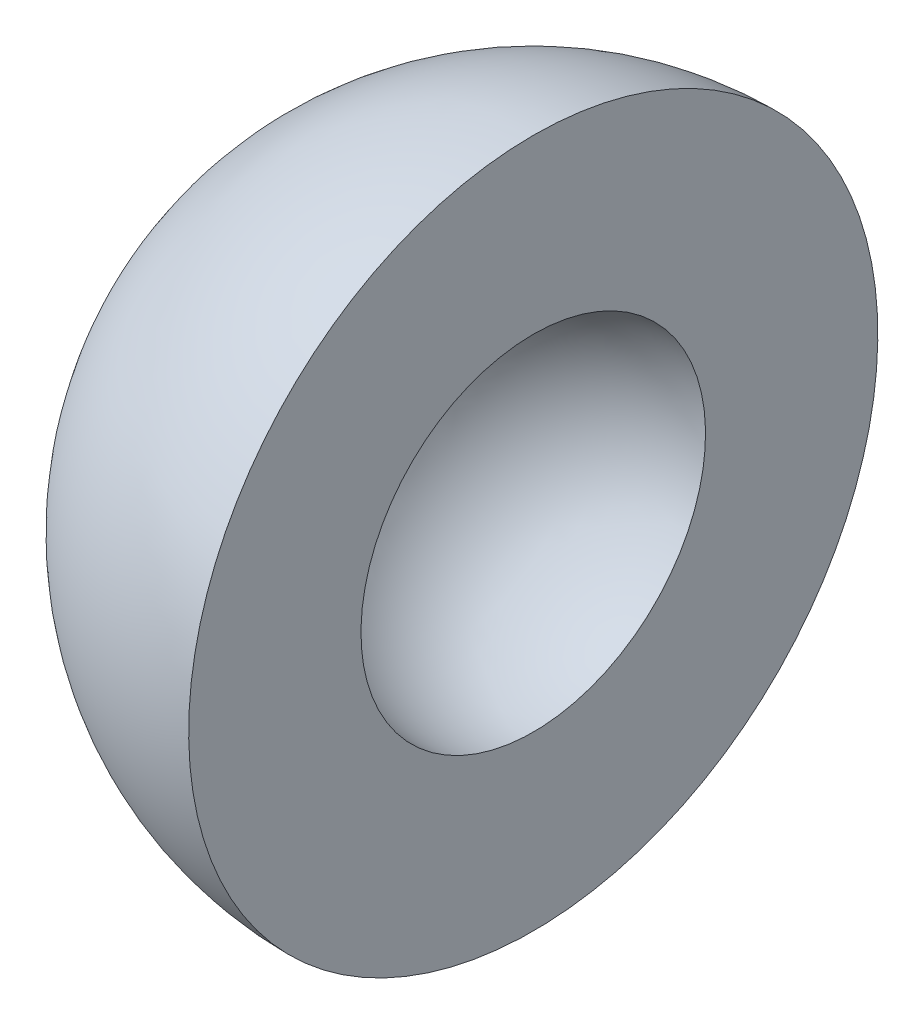
from build123d import *


with BuildPart() as part:
    # Sketch3 → Revolve1 (revolve)
    with BuildSketch(Plane.XY):
        with BuildLine():
            Line((-30, 0), (-15, 0))
            ThreePointArc((-15, 0), (-10.606601718, 10.606601718), (0, 15))
            Line((0, 15), (0, 30))
            ThreePointArc((0, 30), (-21.213203436, 21.213203436), (-30, 0))
        make_face()
    revolve(axis=Axis((0, 0, 0), (-1, 0, 0)))


solid = part.part
